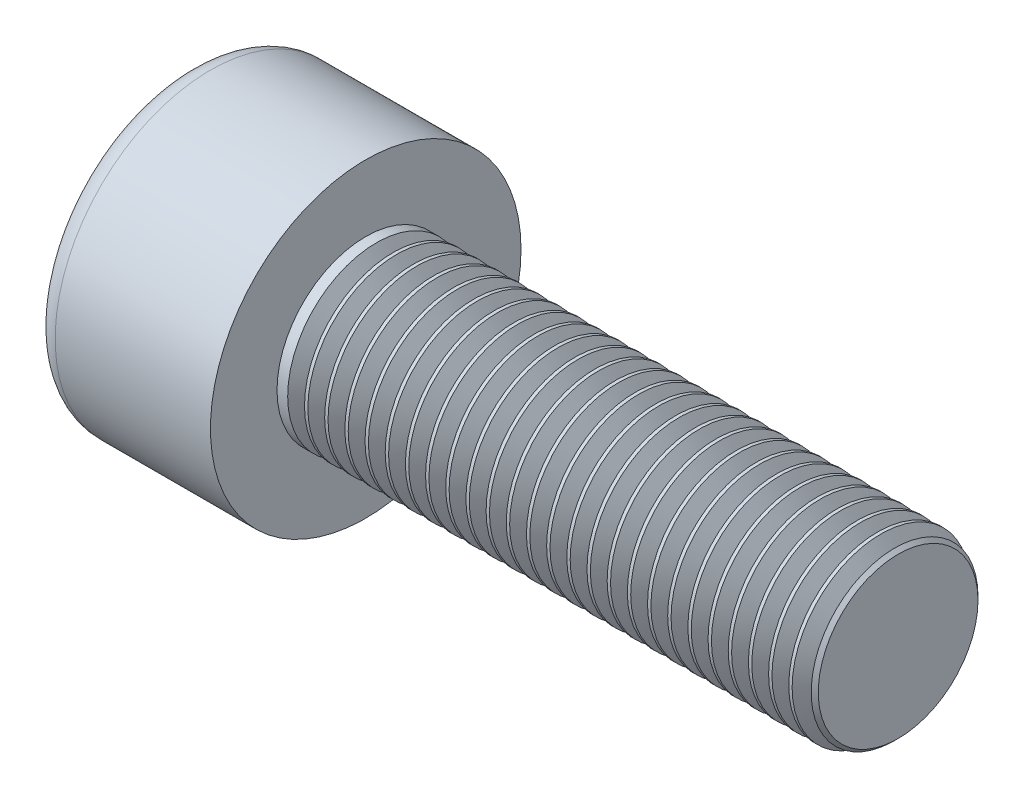
from build123d import *

# Parameters (mm, degrees)
SKETCH1_R           = 3.5
BASEHEAD_DEPTH      = 4
SKETCH2_R           = 2
BASEBODY_DEPTH      = 12
HEXAGONSOCKET_DEPTH = 2
TOPFILLET_R         = 0.5
CHAMFER1_SIZE       = 0.2
LPATTERN10_COUNT    = 26
LPATTERN10_PITCH    = 0.4548


with BuildPart() as part:
    # Sketch1 → BaseHead (new body)
    with BuildSketch(Plane(origin=(0, 0, 0), x_dir=(0, 0, -1), z_dir=(1, 0, 0))):
        Circle(SKETCH1_R)
    extrude(amount=BASEHEAD_DEPTH)

    # Sketch2 → BaseBody (add)
    with BuildSketch(Plane(origin=(4, 0, 0), x_dir=(0, 0, -1), z_dir=(1, 0, 0))):
        Circle(SKETCH2_R)
    extrude(amount=BASEBODY_DEPTH)

    # Sketch3 → HexagonSocket (cut)
    with BuildSketch(Plane(origin=(0, 0, 0), x_dir=(0, 0, -1), z_dir=(1, 0, 0))):
        Polygon((1.732050808, 0), (0.866025404, 1.5), (-0.866025404, 1.5), (-1.732050808, 0), (-0.866025404, -1.5), (0.866025404, -1.5), align=None)
    extrude(amount=HEXAGONSOCKET_DEPTH, mode=Mode.SUBTRACT)

    # Sketch4 → Cut-Revolve1 (revolve, cut)
    with BuildSketch(Plane(origin=(-4.19613823, 0.75, 0), x_dir=(-1, 0, 0), z_dir=(0, 0, 1))):
        Polygon((-6.19613823, 2.25), (-7.062163633, 0.75), (-6.19613823, 0.75), align=None)
    revolve(axis=Axis((0.838992387, 0, 0), (-1, 0, 0)), mode=Mode.SUBTRACT)

    # TopFillet
    topfillet_edges = [part.edges().sort_by_distance(p)[0] for p in [
        (0, 0, 3.5),
    ]]
    fillet(topfillet_edges, radius=TOPFILLET_R)

    # Chamfer1
    chamfer1_edges = [part.edges().sort_by_distance(p)[0] for p in [
        (16, 0, 2),
    ]]
    chamfer(chamfer1_edges, length=CHAMFER1_SIZE)

    # Sketch5 → Cut-Revolve10 (revolve, cut)
    with BuildSketch(Plane.XY):
        Polygon((15.8, 1.671776372), (15.9895, 2), (15.9895, 2.379), (15.6105, 2.379), (15.6105, 2), align=None)
    cut_revolve10 = revolve(axis=Axis((0, 0, 0), (1, 0, 0)), mode=Mode.SUBTRACT)

    # LPattern10: Cut-Revolve10 ×26
    with Locations(*[(-i * LPATTERN10_PITCH, 0, 0) for i in range(1, LPATTERN10_COUNT)]):
        add(cut_revolve10, mode=Mode.SUBTRACT)


solid = part.part
